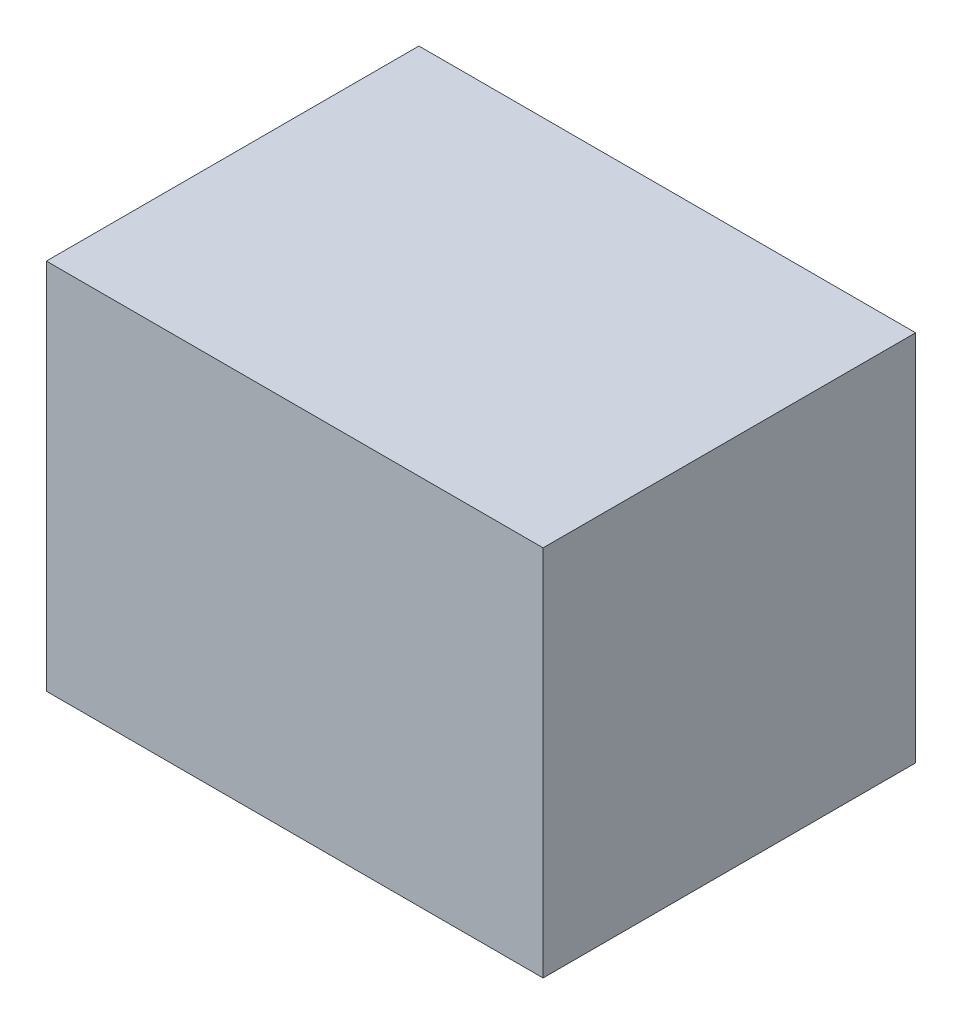
from build123d import *

# Parameters (mm, degrees)
SKETCH2_W           = 4
SKETCH2_H           = 3
BOSS_EXTRUDE1_DEPTH = 3


with BuildPart() as part:
    # Sketch2 → Boss-Extrude1 (new body)
    with BuildSketch(Plane.XY):
        with Locations((2, 1.5)):
            Rectangle(SKETCH2_W, SKETCH2_H)
    extrude(amount=BOSS_EXTRUDE1_DEPTH)


solid = part.part
